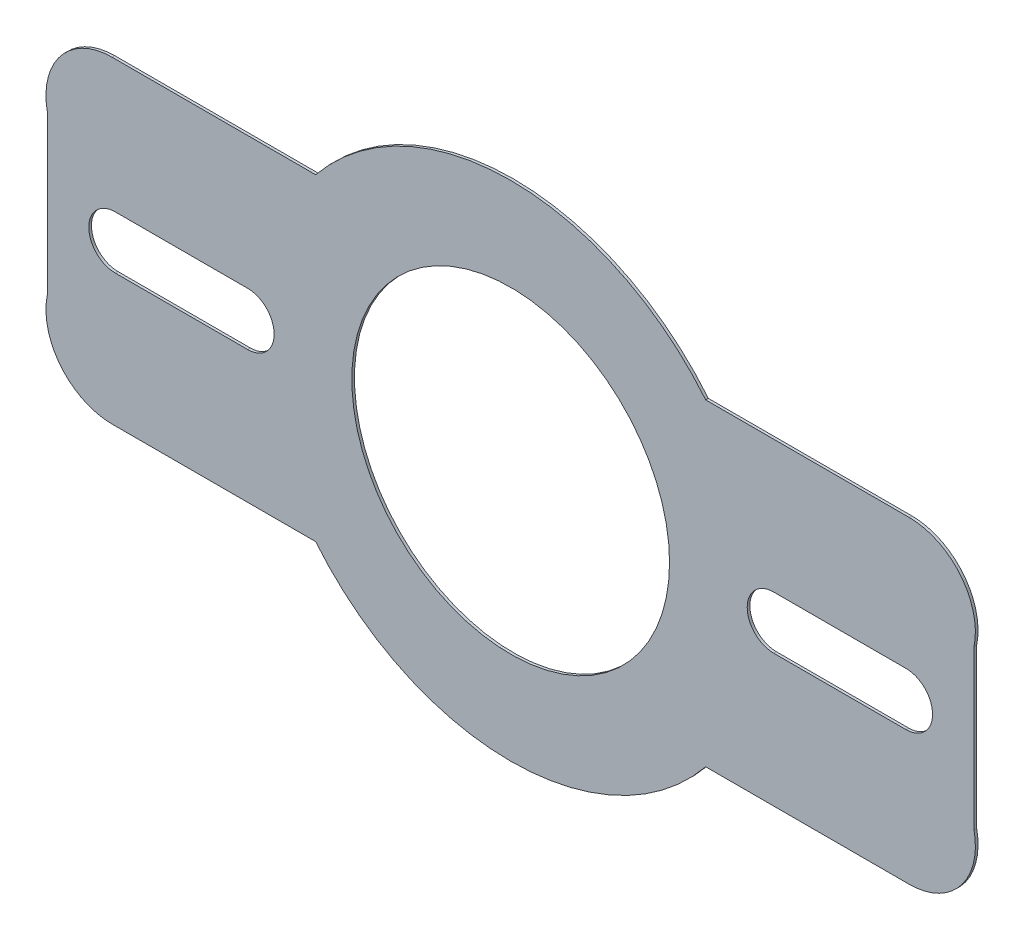
from build123d import *

# Parameters (mm, degrees)
SKETCH1_R           = 60
BOSS_EXTRUDE1_DEPTH = 1


with BuildPart() as part:
    # Sketch1 → Boss-Extrude1 (new body)
    with BuildSketch(Plane.XY):
        with BuildLine():
            Line((-73.654599313, 60), (-150.505102572, 60))
            ThreePointArc((-150.505102572, 60), (-169.870019303, 50.811388301), (-175, 30))
            Line((-175, 30), (-175, -30))
            ThreePointArc((-175, -30), (-169.870019303, -50.811388301), (-150.505102572, -60))
            Line((-150.505102572, -60), (-73.654599313, -60))
            ThreePointArc((-73.654599313, -60), (0, -95), (73.654599313, -60))
            Line((73.654599313, -60), (150.505102572, -60))
            ThreePointArc((150.505102572, -60), (169.870019303, -50.811388301), (175, -30))
            Line((175, -30), (175, 30))
            ThreePointArc((175, 30), (169.870019303, 50.811388301), (150.505102572, 60))
            Line((150.505102572, 60), (73.654599313, 60))
            ThreePointArc((73.654599313, 60), (0, 95), (-73.654599313, 60))
        make_face()
        Circle(SKETCH1_R, mode=Mode.SUBTRACT)
        with BuildLine():
            Line((-149.327299657, 10), (-99.327299657, 10))
            ThreePointArc((-99.327299657, 10), (-89.327299657, 0), (-99.327299657, -10))
            Line((-99.327299657, -10), (-149.327299657, -10))
            ThreePointArc((-149.327299657, -10), (-159.327299657, 0), (-149.327299657, 10))
        make_face(mode=Mode.SUBTRACT)
        with BuildLine():
            Line((149.327299657, -10), (99.327299657, -10))
            ThreePointArc((99.327299657, -10), (89.327299657, 0), (99.327299657, 10))
            Line((99.327299657, 10), (149.327299657, 10))
            ThreePointArc((149.327299657, 10), (159.327299657, 0), (149.327299657, -10))
        make_face(mode=Mode.SUBTRACT)
    extrude(amount=BOSS_EXTRUDE1_DEPTH)


solid = part.part
